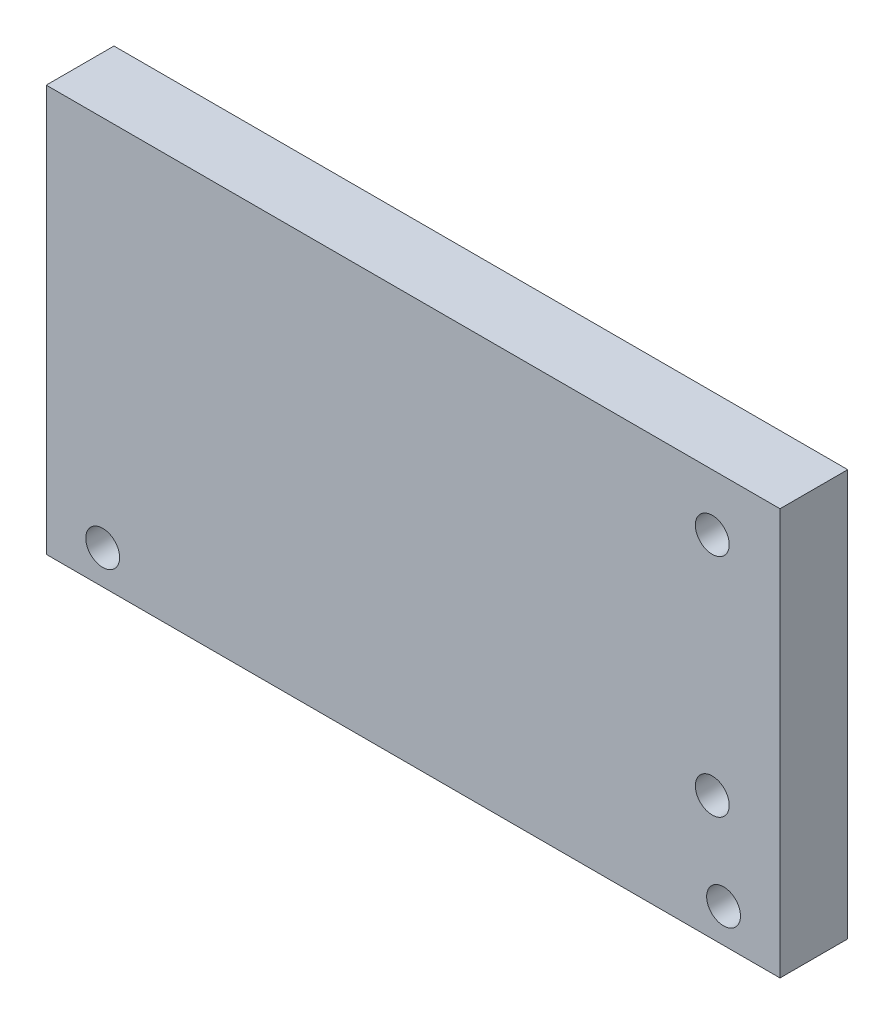
from build123d import *

# Parameters (mm, degrees)
ESQUISSE1_W             = 65
ESQUISSE1_H             = 36
ESQUISSE1_R             = 1.5
BOSS_EXTRU_1_DEPTH      = 6
ESQUISSE3_R             = 1.5
ENL_V_MAT_EXTRU_1_DEPTH = 10


with BuildPart() as part:
    # Esquisse1 → Boss.-Extru.1 (new body)
    with BuildSketch(Plane.XY):
        with Locations((-7.771220945, 18.631944444)):
            Rectangle(ESQUISSE1_W, ESQUISSE1_H)
        with Locations((18.728779055, 31.631944444)):
            Circle(ESQUISSE1_R, mode=Mode.SUBTRACT)
        with Locations((18.728779055, 11.631944444)):
            Circle(ESQUISSE1_R, mode=Mode.SUBTRACT)
    extrude(amount=BOSS_EXTRU_1_DEPTH)

    # Esquisse3 → Enlèv. mat.-Extru.1 (cut)
    with BuildSketch(Plane.XY.offset(6)):
        with Locations((-35.271220945, 3.631944444)):
            Circle(ESQUISSE3_R)
        with Locations((19.728779055, 3.631944444)):
            Circle(ESQUISSE3_R)
    extrude(amount=-ENL_V_MAT_EXTRU_1_DEPTH, mode=Mode.SUBTRACT)


solid = part.part
